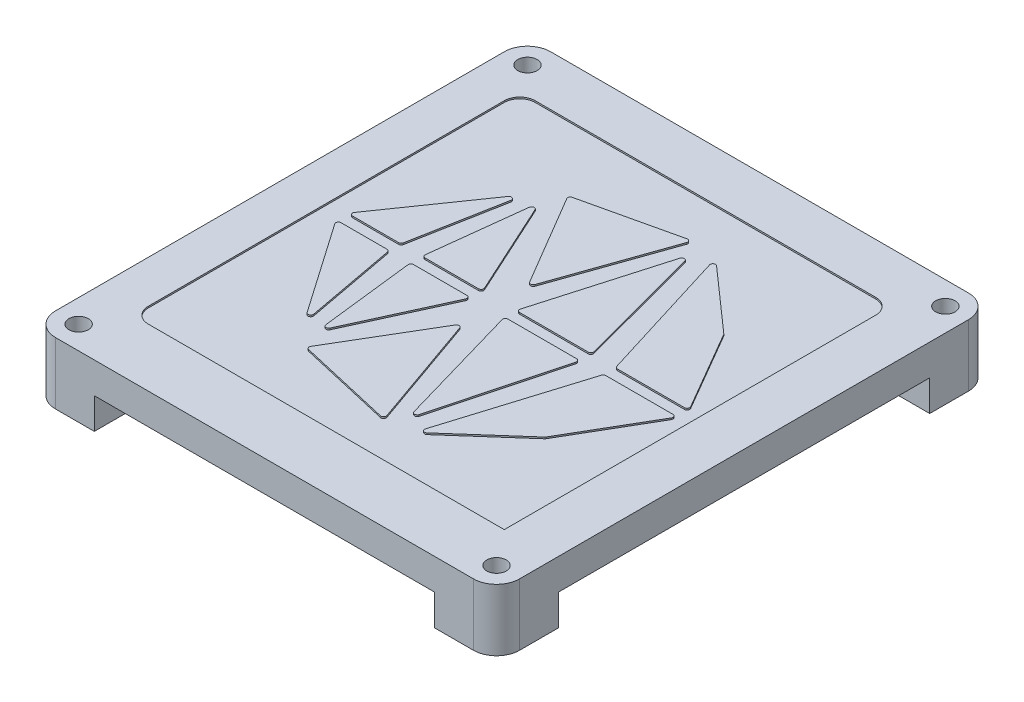
from build123d import *

# Parameters (mm, degrees)
EXTRUDE_1_DEPTH     = 4
EXTRUDE_2_DEPTH     = 4
SKETCH_3_R          = 1.25
CUT_EXTRUDE_1_DEPTH = 15
CUT_EXTRUDE_2_DEPTH = 0.2


with BuildPart() as part:
    # 草图1 → 凸台-拉伸1 (new body)
    with BuildSketch(Plane(origin=(0, 0, 0), x_dir=(1, 0, 0), z_dir=(0, 1, 0))):
        with BuildLine():
            Line((-27.00005461, -31.987363475), (27.00005461, -31.987363475))
            ThreePointArc((27.00005461, -31.987363475), (29.112398272, -31.112402082), (29.987359665, -29.00005842))
            Line((29.987359665, -29.00005842), (29.987359665, 29.00005842))
            ThreePointArc((29.987359665, 29.00005842), (29.112398272, 31.112402082), (27.00005461, 31.987363475))
            Line((27.00005461, 31.987363475), (-27.00005461, 31.987363475))
            ThreePointArc((-27.00005461, 31.987363475), (-29.112398272, 31.112402082), (-29.987359665, 29.00005842))
            Line((-29.987359665, 29.00005842), (-29.987359665, -29.00005842))
            ThreePointArc((-29.987359665, -29.00005842), (-29.112398272, -31.112402082), (-27.00005461, -31.987363475))
        make_face()
    extrude(amount=EXTRUDE_1_DEPTH)

    # 草图2 → 凸台-拉伸2 (add)
    with BuildSketch(Plane.XZ):
        with BuildLine():
            Line((-21.987359665, 23.987363475), (-21.987359665, 31.987363475))
            Line((-21.987359665, 31.987363475), (-27.00005461, 31.987363475))
            ThreePointArc((-27.00005461, 31.987363475), (-29.112398272, 31.112402082), (-29.987359665, 29.00005842))
            Line((-29.987359665, 29.00005842), (-29.987359665, 23.987363475))
            Line((-29.987359665, 23.987363475), (-21.987359665, 23.987363475))
        make_face()
        with BuildLine():
            Line((21.987359665, -23.987363475), (21.987359665, -31.987363475))
            Line((21.987359665, -31.987363475), (27.00005461, -31.987363475))
            ThreePointArc((27.00005461, -31.987363475), (29.112398272, -31.112402082), (29.987359665, -29.00005842))
            Line((29.987359665, -29.00005842), (29.987359665, -23.987363475))
            Line((29.987359665, -23.987363475), (21.987359665, -23.987363475))
        make_face()
        with BuildLine():
            Line((21.987359665, 23.987363475), (29.987359665, 23.987363475))
            Line((29.987359665, 23.987363475), (29.987359665, 29.00005842))
            ThreePointArc((29.987359665, 29.00005842), (29.112398272, 31.112402082), (27.00005461, 31.987363475))
            Line((27.00005461, 31.987363475), (21.987359665, 31.987363475))
            Line((21.987359665, 31.987363475), (21.987359665, 23.987363475))
        make_face()
        with BuildLine():
            Line((-29.987359665, -23.987363475), (-29.987359665, -29.00005842))
            ThreePointArc((-29.987359665, -29.00005842), (-29.112398272, -31.112402082), (-27.00005461, -31.987363475))
            Line((-27.00005461, -31.987363475), (-21.987359665, -31.987363475))
            Line((-21.987359665, -31.987363475), (-21.987359665, -23.987363475))
            Line((-21.987359665, -23.987363475), (-29.987359665, -23.987363475))
        make_face()
    extrude(amount=EXTRUDE_2_DEPTH)

    # 草图3 → 切除-拉伸1 (cut)
    with BuildSketch(Plane.XZ.offset(4)):
        with Locations((-27.00005461, 29.00005842)):
            Circle(SKETCH_3_R)
        with Locations((27.00005461, 29.00005842)):
            Circle(SKETCH_3_R)
        with Locations((27.00005461, -29.00005842)):
            Circle(SKETCH_3_R)
        with Locations((-27.00005461, -29.00005842)):
            Circle(SKETCH_3_R)
    extrude(amount=-CUT_EXTRUDE_1_DEPTH, mode=Mode.SUBTRACT)

    # 草图5 → 切除-拉伸2 (cut)
    with BuildSketch(Plane(origin=(0, 4, 0), x_dir=(1, 0, 0), z_dir=(0, 1, 0))):
        with BuildLine():
            ThreePointArc((-24.510212589, -22.489370571), (-23.924426151, -23.903584133), (-22.510212589, -24.489370571))
            Line((-22.510212589, -24.489370571), (23.489787411, -24.489370571))
            Line((23.489787411, -24.489370571), (23.489787411, 23.510629429))
            ThreePointArc((23.489787411, 23.510629429), (22.904000974, 24.924842991), (21.489787411, 25.510629429))
            Line((21.489787411, 25.510629429), (-22.510212589, 25.510629429))
            ThreePointArc((-22.510212589, 25.510629429), (-23.924426151, 24.924842991), (-24.510212589, 23.510629429))
            Line((-24.510212589, 23.510629429), (-24.510212589, -22.489370571))
        make_face()
        with BuildLine():
            Line((-21.404655137, -0.688500192), (-15.457204068, -0.688500192))
            ThreePointArc((-15.457204068, -0.688500192), (-15.242140256, -0.766165613), (-15.126321966, -0.963321604))
            Line((-15.126321966, -0.963321604), (-12.93890785, -12.678969469))
            ThreePointArc((-12.93890785, -12.678969469), (-13.010855373, -12.95581187), (-13.269789952, -13.077348057))
            ThreePointArc((-13.269789952, -13.077348057), (-13.425801703, -13.039009509), (-13.546274154, -12.932727342))
            Line((-13.546274154, -12.932727342), (-21.681139339, -1.217079478))
            ThreePointArc((-21.681139339, -1.217079478), (-21.702916589, -0.869088442), (-21.404655137, -0.688500192))
        make_face(mode=Mode.SUBTRACT)
        with BuildLine():
            Line((-9.512596077, -16.472848359), (-2.571281975, -4.734690874))
            ThreePointArc((-2.571281975, -4.734690874), (-2.248646777, -4.571034999), (-1.964018884, -4.794336767))
            Line((-1.964018884, -4.794336767), (3.140150939, -19.305798562))
            ThreePointArc((3.140150939, -19.305798562), (3.097295639, -19.61204324), (2.822620241, -19.754084802))
            ThreePointArc((2.822620241, -19.754084802), (2.784616416, -19.75193251), (2.7470986, -19.745503158))
            Line((2.7470986, -19.745503158), (-9.298385325, -16.972198847))
            ThreePointArc((-9.298385325, -16.972198847), (-9.53220226, -16.77688017), (-9.512596077, -16.472848359))
        make_face(mode=Mode.SUBTRACT)
        with BuildLine():
            Line((-12.041068111, -0.688500192), (-5.131124443, -0.688500192))
            ThreePointArc((-5.131124443, -0.688500192), (-4.847891187, -0.843225283), (-4.825045876, -1.165155435))
            Line((-4.825045876, -1.165155435), (-10.329425017, -13.194497943))
            ThreePointArc((-10.329425017, -13.194497943), (-10.453628675, -13.337675957), (-10.635503584, -13.391042701))
            ThreePointArc((-10.635503584, -13.391042701), (-10.859278656, -13.305887083), (-10.969829102, -13.093506855))
            Line((-10.969829102, -13.093506855), (-12.375393629, -1.064164346))
            ThreePointArc((-12.375393629, -1.064164346), (-12.292512493, -0.80132512), (-12.041068111, -0.688500192))
        make_face(mode=Mode.SUBTRACT)
        with BuildLine():
            Line((9.36207412, -1.111559506), (5.109122277, -17.113456876))
            ThreePointArc((5.109122277, -17.113456876), (4.988995356, -17.293832498), (4.783815734, -17.363597563))
            ThreePointArc((4.783815734, -17.363597563), (4.581434131, -17.295960844), (4.460386024, -17.120232659))
            Line((4.460386024, -17.120232659), (-0.152481619, -1.118335289))
            ThreePointArc((-0.152481619, -1.118335289), (-0.098015191, -0.822718589), (0.17094809, -0.688500192))
            Line((0.17094809, -0.688500192), (9.036767577, -0.688500192))
            ThreePointArc((9.036767577, -0.688500192), (9.303602512, -0.81992057), (9.36207412, -1.111559506))
        make_face(mode=Mode.SUBTRACT)
        with BuildLine():
            Line((12.808517611, -0.688500192), (21.484169915, -0.688500192))
            ThreePointArc((21.484169915, -0.688500192), (21.775984057, -0.857338258), (21.775051109, -1.194474604))
            Line((21.775051109, -1.194474604), (15.823663685, -11.415302329))
            ThreePointArc((15.823663685, -11.415302329), (15.793013116, -11.45942167), (15.755733936, -11.498102884))
            Line((15.755733936, -11.498102884), (7.668279808, -18.648335147))
            ThreePointArc((7.668279808, -18.648335147), (7.564528755, -18.710947136), (7.445328364, -18.732760181))
            ThreePointArc((7.445328364, -18.732760181), (7.174474873, -18.596004987), (7.123708261, -18.296862298))
            Line((7.123708261, -18.296862298), (12.486897508, -0.92580231))
            ThreePointArc((12.486897508, -0.92580231), (12.608672805, -0.754246701), (12.808517611, -0.688500192))
        make_face(mode=Mode.SUBTRACT)
        with BuildLine():
            Line((-21.681139339, 1.332693738), (-13.546274154, 13.048341603))
            ThreePointArc((-13.546274154, 13.048341603), (-13.14002845, 13.166944855), (-12.93890785, 12.794583729))
            Line((-12.93890785, 12.794583729), (-15.126321966, 1.078935865))
            ThreePointArc((-15.126321966, 1.078935865), (-15.242140256, 0.881779873), (-15.457204068, 0.804114453))
            Line((-15.457204068, 0.804114453), (-21.404655137, 0.804114453))
            ThreePointArc((-21.404655137, 0.804114453), (-21.702916589, 0.984702702), (-21.681139339, 1.332693738))
        make_face(mode=Mode.SUBTRACT)
        with BuildLine():
            Line((-12.375393629, 1.179778607), (-10.969829102, 13.209121115))
            ThreePointArc((-10.969829102, 13.209121115), (-10.68793709, 13.502547995), (-10.329425017, 13.310112203))
            Line((-10.329425017, 13.310112203), (-4.825045876, 1.280769695))
            ThreePointArc((-4.825045876, 1.280769695), (-4.847891187, 0.958839543), (-5.131124443, 0.804114453))
            Line((-5.131124443, 0.804114453), (-12.041068111, 0.804114453))
            ThreePointArc((-12.041068111, 0.804114453), (-12.292512493, 0.916939381), (-12.375393629, 1.179778607))
        make_face(mode=Mode.SUBTRACT)
        with BuildLine():
            Line((-2.571281975, 4.850305134), (-9.512596077, 16.588462619))
            ThreePointArc((-9.512596077, 16.588462619), (-9.53220226, 16.89249443), (-9.298385325, 17.087813107))
            Line((-9.298385325, 17.087813107), (2.7470986, 19.861117418))
            ThreePointArc((2.7470986, 19.861117418), (3.073572684, 19.75742568), (3.140150939, 19.421412823))
            Line((3.140150939, 19.421412823), (-1.964018884, 4.909951027))
            ThreePointArc((-1.964018884, 4.909951027), (-2.086991143, 4.746961869), (-2.281549581, 4.685037267))
            ThreePointArc((-2.281549581, 4.685037267), (-2.448326624, 4.729259125), (-2.571281975, 4.850305134))
        make_face(mode=Mode.SUBTRACT)
        with BuildLine():
            Line((9.036767577, 0.804114453), (0.17094809, 0.804114453))
            ThreePointArc((0.17094809, 0.804114453), (-0.098015191, 0.93833285), (-0.152481619, 1.233949549))
            Line((-0.152481619, 1.233949549), (4.460386024, 17.235846919))
            ThreePointArc((4.460386024, 17.235846919), (4.78733119, 17.479193465), (5.109122277, 17.229071137))
            Line((5.109122277, 17.229071137), (9.36207412, 1.227173766))
            ThreePointArc((9.36207412, 1.227173766), (9.303602512, 0.93553483), (9.036767577, 0.804114453))
        make_face(mode=Mode.SUBTRACT)
        with BuildLine():
            Line((21.484169915, 0.804114453), (12.808517611, 0.804114453))
            ThreePointArc((12.808517611, 0.804114453), (12.608672805, 0.869860962), (12.486897508, 1.04141657))
            Line((12.486897508, 1.04141657), (7.123708261, 18.412476559))
            ThreePointArc((7.123708261, 18.412476559), (7.262798457, 18.794586027), (7.668279808, 18.763949407))
            Line((7.668279808, 18.763949407), (15.755733936, 11.613717144))
            ThreePointArc((15.755733936, 11.613717144), (15.793013116, 11.57503593), (15.823663685, 11.53091659))
            Line((15.823663685, 11.53091659), (21.775051109, 1.310088864))
            ThreePointArc((21.775051109, 1.310088864), (21.775984057, 0.972952518), (21.484169915, 0.804114453))
        make_face(mode=Mode.SUBTRACT)
    extrude(amount=-CUT_EXTRUDE_2_DEPTH, mode=Mode.SUBTRACT)


solid = part.part
